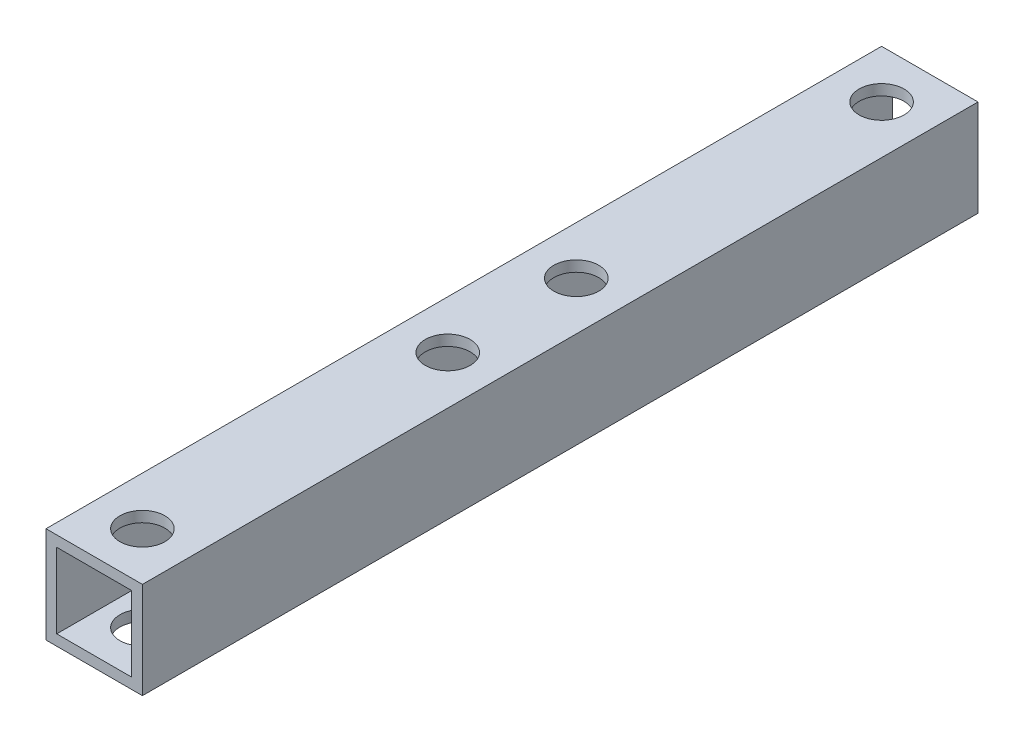
from build123d import *

# Parameters (mm, degrees)
SKETCH_1_W          = 9
SKETCH_1_H          = 9
EXTRUDE_1_DEPTH     = 78
SKETCH_2_W          = 7
SKETCH_2_H          = 7
CUT_EXTRUDE_1_DEPTH = 78
SKETCH_3_R          = 2.1
CUT_EXTRUDE_2_DEPTH = 75
SKETCH_4_R          = 2.1
CUT_EXTRUDE_3_DEPTH = 75


with BuildPart() as part:
    # ｽｹｯﾁ1 → ﾎﾞｽ - 押し出し1 (new body)
    with BuildSketch(Plane.XY):
        Rectangle(SKETCH_1_W, SKETCH_1_H)
    extrude(amount=EXTRUDE_1_DEPTH)

    # ｽｹｯﾁ2 → ｶｯﾄ - 押し出し1 (cut)
    with BuildSketch(Plane.XY.offset(78)):
        Rectangle(SKETCH_2_W, SKETCH_2_H)
    extrude(amount=-CUT_EXTRUDE_1_DEPTH, mode=Mode.SUBTRACT)

    # ｽｹｯﾁ3 → ｶｯﾄ - 押し出し2 (cut)
    with BuildSketch(Plane(origin=(0, 4.5, 0), x_dir=(1, 0, 0), z_dir=(0, 1, 0))):
        with Locations((0, -4.5)):
            Circle(SKETCH_3_R)
        with Locations((0, -73.5)):
            Circle(SKETCH_3_R)
    extrude(amount=-CUT_EXTRUDE_2_DEPTH, mode=Mode.SUBTRACT)

    # ｽｹｯﾁ4 → ｶｯﾄ - 押し出し3 (cut)
    with BuildSketch(Plane(origin=(0, 4.5, 0), x_dir=(1, 0, 0), z_dir=(0, 1, 0))):
        with Locations((0, -33)):
            Circle(SKETCH_4_R)
        with Locations((0, -45)):
            Circle(SKETCH_4_R)
    extrude(amount=-CUT_EXTRUDE_3_DEPTH, mode=Mode.SUBTRACT)


solid = part.part
